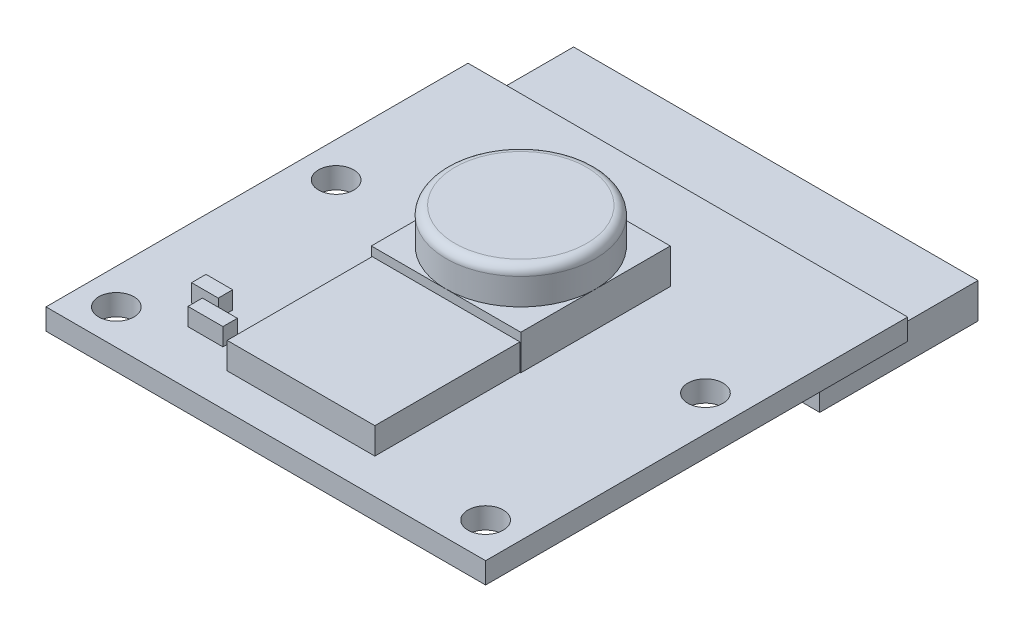
from build123d import *

# Parameters (mm, degrees)
SKETCH1_W           = 25
SKETCH1_H           = 24
SKETCH1_R           = 1
BOSS_EXTRUDE1_DEPTH = 1.2
BOSS_EXTRUDE2_START = 1.2
BOSS_EXTRUDE2_DEPTH = 1.5
BOSS_EXTRUDE3_START = 1.2
SKETCH1_4_W         = 8.5
SKETCH1_4_H         = 8.5
BOSS_EXTRUDE3_DEPTH = 2
BOSS_EXTRUDE4_START = 1.2
SKETCH1_5_W         = 1.516820611
SKETCH1_5_H         = 0.819903033
SKETCH1_5_W_2       = 1.988264855
BOSS_EXTRUDE4_DEPTH = 1
SKETCH1_6_W         = 23
SKETCH1_6_H         = 4
SKETCH1_6_H_2       = 5
BOSS_EXTRUDE5_DEPTH = 2
BOSS_EXTRUDE6_START = 3.2
SKETCH1_7_R         = 4.25
BOSS_EXTRUDE6_DEPTH = 2
FILLET1_R           = 0.5


with BuildPart() as part:
    # Sketch1 → Boss-Extrude1 (new body)
    with BuildSketch(Plane(origin=(0, 0, 0), x_dir=(1, 0, 0), z_dir=(0, 1, 0))):
        with Locations((12.5, 12)):
            Rectangle(SKETCH1_W, SKETCH1_H)
        with Locations((2, 2)):
            Circle(SKETCH1_R, mode=Mode.SUBTRACT)
        with Locations((23, 2)):
            Circle(SKETCH1_R, mode=Mode.SUBTRACT)
        with Locations((2, 14.5)):
            Circle(SKETCH1_R, mode=Mode.SUBTRACT)
        with Locations((23, 14.5)):
            Circle(SKETCH1_R, mode=Mode.SUBTRACT)
    extrude(amount=BOSS_EXTRUDE1_DEPTH)

    # Sketch1_3 → Boss-Extrude2 (add)
    with BuildSketch(Plane(origin=(0, 0, 0), x_dir=(1, 0, 0), z_dir=(0, 1, 0)).offset(BOSS_EXTRUDE2_START)):
        Polygon((16.7, 10.25), (12.5, 10.25), (8.3, 10.25), (8.3, 2), (16.7, 2), align=None)
    extrude(amount=BOSS_EXTRUDE2_DEPTH)

    # Sketch1_4 → Boss-Extrude3 (add)
    with BuildSketch(Plane(origin=(0, 0, 0), x_dir=(1, 0, 0), z_dir=(0, 1, 0)).offset(BOSS_EXTRUDE3_START)):
        with Locations((12.5, 14.5)):
            Rectangle(SKETCH1_4_W, SKETCH1_4_H)
    extrude(amount=BOSS_EXTRUDE3_DEPTH)

    # Sketch1_5 → Boss-Extrude4 (add)
    with BuildSketch(Plane(origin=(0, 0, 0), x_dir=(1, 0, 0), z_dir=(0, 1, 0)).offset(BOSS_EXTRUDE4_START)):
        with Locations((4.706273263, 4.74063197)):
            Rectangle(SKETCH1_5_W, SKETCH1_5_H)
        with Locations((6.007869327, 3.469782269)):
            Rectangle(SKETCH1_5_W_2, SKETCH1_5_H)
    extrude(amount=BOSS_EXTRUDE4_DEPTH)

    # Sketch1_6 → Boss-Extrude5 (add)
    with BuildSketch(Plane(origin=(0, 0, 0), x_dir=(1, 0, 0), z_dir=(0, 1, 0))):
        with Locations((12.5, 22)):
            Rectangle(SKETCH1_6_W, SKETCH1_6_H)
        with Locations((12.5, 26.5)):
            Rectangle(SKETCH1_6_W, SKETCH1_6_H_2)
    extrude(amount=-BOSS_EXTRUDE5_DEPTH)

    # Sketch1_7 → Boss-Extrude6 (add)
    with BuildSketch(Plane(origin=(0, 0, 0), x_dir=(1, 0, 0), z_dir=(0, 1, 0)).offset(BOSS_EXTRUDE6_START)):
        with Locations((12.5, 14.5)):
            Circle(SKETCH1_7_R)
    extrude(amount=BOSS_EXTRUDE6_DEPTH)

    # Fillet1
    fillet1_edges = [part.edges().sort_by_distance(p)[0] for p in [
        (8.25, 5.2, -14.5),
    ]]
    fillet(fillet1_edges, radius=FILLET1_R)


solid = part.part
